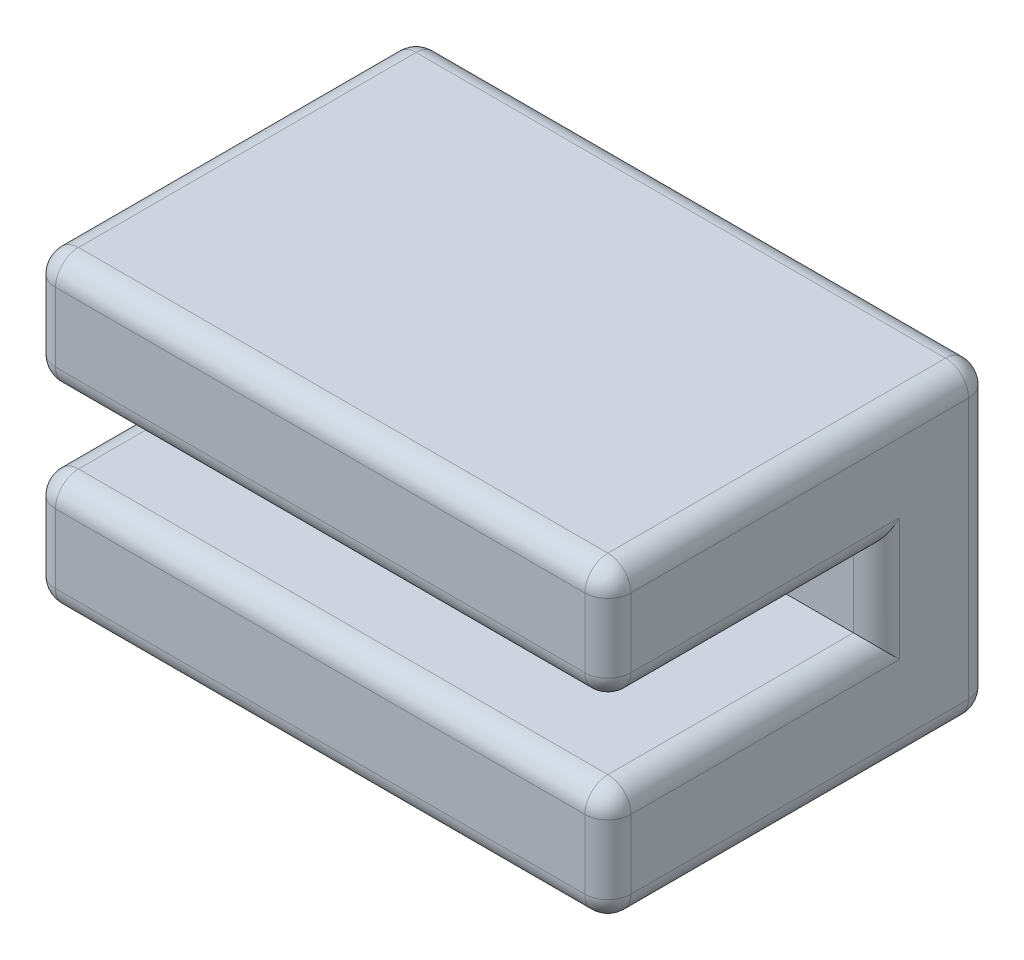
from build123d import *

# Parameters (mm, degrees)
SKETCH1_W           = 15
SKETCH1_H           = 8
BOSS_EXTRUDE1_DEPTH = 10
SKETCH2_W           = 15
SKETCH2_H           = 2
CUT_EXTRUDE1_DEPTH  = 7
FILLET1_R           = 0.6


with BuildPart() as part:
    # Sketch1 → Boss-Extrude1 (new body)
    with BuildSketch(Plane.XY):
        with Locations((-7.5, 4)):
            Rectangle(SKETCH1_W, SKETCH1_H)
    extrude(amount=BOSS_EXTRUDE1_DEPTH)

    # Sketch2 → Cut-Extrude1 (cut)
    with BuildSketch(Plane.XY.offset(10)):
        with Locations((-7.5, 4)):
            Rectangle(SKETCH2_W, SKETCH2_H)
    extrude(amount=-CUT_EXTRUDE1_DEPTH, mode=Mode.SUBTRACT)

    # Fillet1
    fillet1_edges = [part.edges().sort_by_distance(p)[0] for p in [
        (-15, 6.5, 10),
        (0, 6.5, 10),
        (-15, 1.5, 10),
        (-7.5, 0, 10),
        (-15, 4, 3),
        (-15, 3, 6.5),
        (-15, 5, 6.5),
        (0, 4, 3),
        (0, 5, 6.5),
        (0, 3, 6.5),
        (-7.5, 3, 10),
        (-7.5, 5, 10),
        (0, 1.5, 10),
        (-7.5, 0, 0),
        (-15, 4, 0),
        (-7.5, 8, 0),
        (0, 4, 0),
        (0, 0, 5),
        (-15, 0, 5),
        (-15, 8, 5),
        (0, 8, 5),
        (-7.5, 8, 10),
    ]]
    fillet(fillet1_edges, radius=FILLET1_R)


solid = part.part
